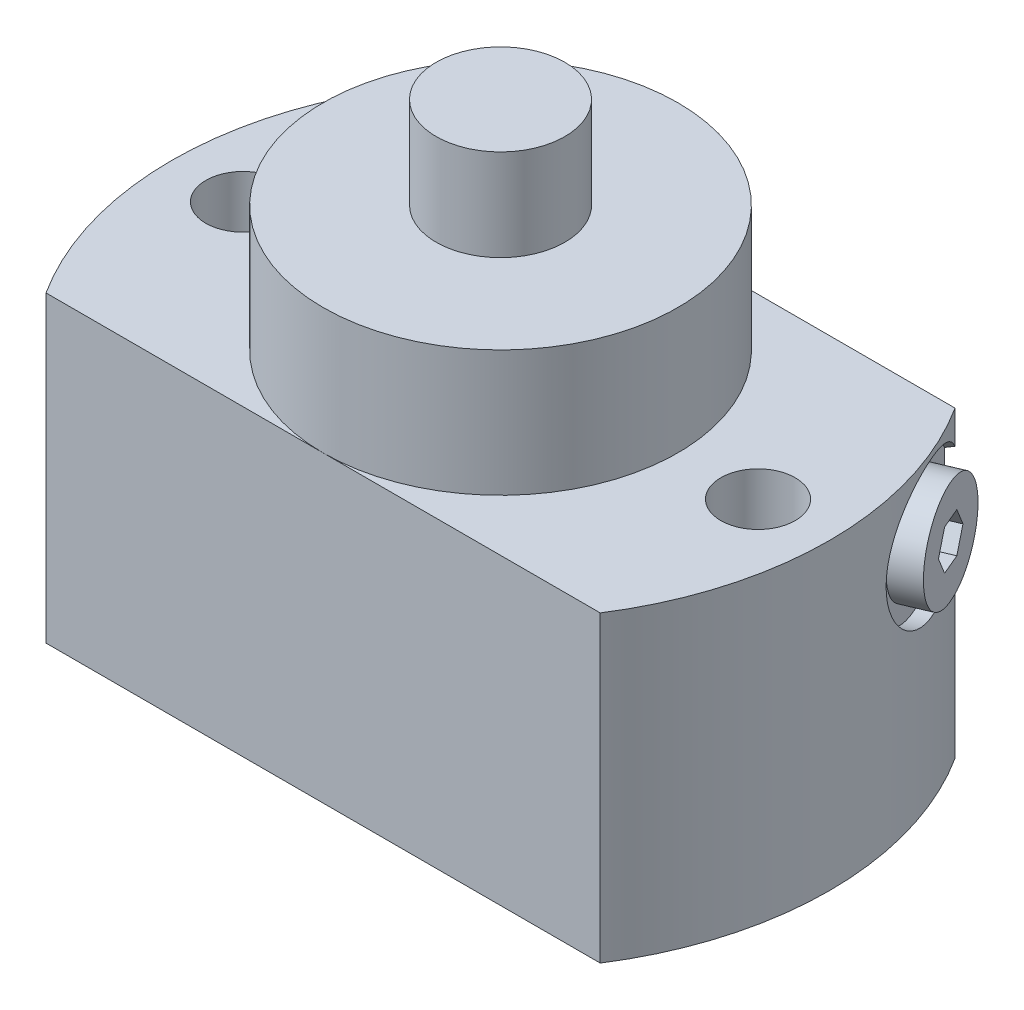
from build123d import *

# Parameters (mm, degrees)
EXTRUDE1_DEPTH     = 53
HOLE1_D            = 13
HOLE1_DEPTH        = 53
SKETCH5_R          = 4
CUT_EXTRUDE1_DEPTH = 4
SKETCH6_R          = 5.5
CUT_EXTRUDE2_DEPTH = 3
SKETCH7_R          = 2
CUT_EXTRUDE3_DEPTH = 33
CUT_EXTRUDE4_DEPTH = 5


with BuildPart() as part:
    # Sketch1 → Extrude1 (new body)
    with BuildSketch(Plane(origin=(0, 0, 0), x_dir=(1, 0, 0), z_dir=(0, 1, 0))):
        with BuildLine():
            Line((-48.427781283, 31), (48.427781283, 31))
            ThreePointArc((48.427781283, 31), (57.5, 0), (48.427781283, -31))
            Line((48.427781283, -31), (-48.427781283, -31))
            ThreePointArc((-48.427781283, -31), (-57.5, 0), (-48.427781283, 31))
        make_face()
    extrude(amount=EXTRUDE1_DEPTH)

    # Sketch2 → Revolve1 (revolve)
    with BuildSketch(Plane.XY, mode=Mode.PRIVATE) as revolve1_sk:
        Polygon((0, 91), (-11.25, 91), (-11.25, 75), (-31, 75), (-31, 53), (0, 53), align=None)
    revolve(revolve1_sk.sketch.rotate(Axis((0, 0, 0), (0, 1, 0)), 270), axis=Axis((0, 0, 0), (0, 1, 0)))  # turned: the seam where the file's is

    # Hole1
    with Locations(Plane(origin=(0, 53, 0), x_dir=(-1, 0, 0), z_dir=(0, 1, 0))):
        with Locations((45, 0), (-45, 0)):
            Hole(HOLE1_D / 2, depth=HOLE1_DEPTH)

    # Sketch5 → Cut-Extrude1 (cut)
    with BuildSketch(Plane.XZ):
        with Locations(Location((0, 0, 0), (0, 0, 270))):  # turned: the seam where the file's is
            Circle(SKETCH5_R)
    extrude(amount=-CUT_EXTRUDE1_DEPTH, mode=Mode.SUBTRACT)

    # Sketch6 → Cut-Extrude2 (cut)
    with BuildSketch(Plane.XZ):
        with Locations(Location((35, -15, 0), (0, 0, 270))):  # turned: the seam where the file's is
            Circle(SKETCH6_R)
    extrude(amount=-CUT_EXTRUDE2_DEPTH, mode=Mode.SUBTRACT)

    # Sketch7 → Cut-Extrude3 (cut)
    with BuildSketch(Plane.XZ.offset(-3)):
        with Locations(Location((35, -15, 0), (0, 0, 270))):  # turned: the seam where the file's is
            Circle(SKETCH7_R)
    extrude(amount=-CUT_EXTRUDE3_DEPTH, mode=Mode.SUBTRACT)

    # Sketch8 → Cut-Revolve1 (revolve, cut)
    with BuildSketch(Plane(origin=(0, 0, 0), x_dir=(0.920504853, 0, -0.390731128), z_dir=(0.390731128, 0, 0.920504853)), mode=Mode.PRIVATE) as cut_revolve1_sk:
        Polygon((57.5, 28), (55, 28), (55, 33.4215), (53.517364509, 34.2775), (35, 34.2775), (35, 40), (57.5, 40), align=None)
    revolve(cut_revolve1_sk.sketch.rotate(Axis((47.484793311, 40, -20.156098913), (-0.920504853, 0, 0.390731128)), 270), axis=Axis((47.484793311, 40, -20.156098913), (-0.920504853, 0, 0.390731128)), mode=Mode.SUBTRACT)  # turned: the seam where the file's is

    # Sketch9 → Revolve2 (revolve)
    with BuildSketch(Plane(origin=(0, 0, 0), x_dir=(0.920504853, 0, -0.390731128), z_dir=(0.390731128, 0, 0.920504853)), mode=Mode.PRIVATE) as revolve2_sk:
        Polygon((55, 31), (55, 34.2775), (46, 34.2775), (45, 35.2775), (45, 40), (60, 40), (60, 31), align=None)
    revolve(revolve2_sk.sketch.rotate(Axis((68.658528533, 40, -29.14381628), (-0.920504853, 0, 0.390731128)), 270), axis=Axis((68.658528533, 40, -29.14381628), (-0.920504853, 0, 0.390731128)))  # turned: the seam where the file's is

    # Sketch10 → Cut-Extrude4 (cut)
    with BuildSketch(Plane(origin=(55.230291207, 0, -23.443867709), x_dir=(-0.390731128, 0, -0.920504853), z_dir=(0.920504853, 0, -0.390731128))):
        Polygon((4.041451884, 40), (2.020725942, 43.5), (-2.020725942, 43.5), (-4.041451884, 40), (-2.020725942, 36.5), (2.020725942, 36.5), align=None)
    extrude(amount=-CUT_EXTRUDE4_DEPTH, mode=Mode.SUBTRACT)


solid = part.part
